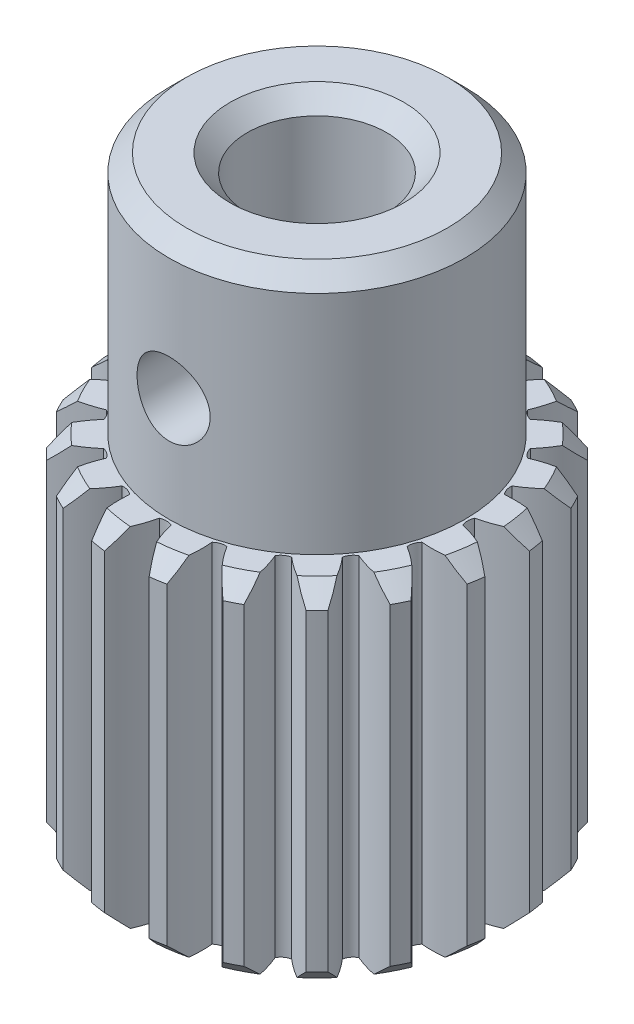
from build123d import *

# Parameters (mm, degrees)
SKETCH_1_R               = 11
EXTRUDE_1_DEPTH          = 20
CUT_EXTRUDE_1_DEPTH      = 21
CHAMFER_1_SIZE           = 1
PATTERN_CIRCULAR_1_COUNT = 20
SKETCH_4_R               = 8.5
EXTRUDE_2_DEPTH          = 14
SKETCH_3_R               = 4
CUT_EXTRUDE_2_DEPTH      = 35
CHAMFER_3_SIZE           = 1
CHAMFER_2_SIZE           = 1
SKETCH_7_W               = 2.1
SKETCH_7_H               = 10.925363506
PATTERN_CIRCULAR_2_COUNT = 2
PATTERN_CIRCULAR_2_ANGLE = 90


with BuildPart() as part:
    # 草圖1 → 填料-伸長1 (new body)
    with BuildSketch(Plane(origin=(0, 0, 0), x_dir=(1, 0, 0), z_dir=(0, 1, 0))):
        Circle(SKETCH_1_R)
    extrude(amount=EXTRUDE_1_DEPTH)

    # 草圖2 → 除料-伸長1 (cut, through all)
    with BuildSketch(Plane(origin=(0, 20, 0), x_dir=(1, 0, 0), z_dir=(0, 1, 0))):
        with BuildLine():
            ThreePointArc((-0.33932507, 8.71883699), (-0.711817342, 9.86361525), (-1.279231123, 10.925363506))
            ThreePointArc((-1.279231123, 10.925363506), (0, 11), (1.279231123, 10.925363506))
            ThreePointArc((1.279231123, 10.925363506), (0.711817342, 9.86361525), (0.33932507, 8.71883699))
            ThreePointArc((0.33932507, 8.71883699), (0, 8.647249963), (-0.33932507, 8.71883699))
        make_face()
    cut_extrude_1 = extrude(amount=-CUT_EXTRUDE_1_DEPTH, mode=Mode.SUBTRACT)

    # 導角1
    chamfer_1_edges = [part.edges().sort_by_distance(p)[0] for p in [
        (0, 0, 11),
        (0, 20, 11),
    ]]
    chamfer(chamfer_1_edges, length=CHAMFER_1_SIZE)

    # 環狀複製排列1: 除料-伸長1 ×20 about axis
    pattern_circular_1_axis = Axis((0, 0, 0), (0, 1, 0))
    for i in range(1, PATTERN_CIRCULAR_1_COUNT):
        add(cut_extrude_1.rotate(pattern_circular_1_axis, i * 360 / PATTERN_CIRCULAR_1_COUNT), mode=Mode.SUBTRACT)

    # 草圖4 → 填料-伸長2 (add)
    with BuildSketch(Plane(origin=(0, 20, 0), x_dir=(1, 0, 0), z_dir=(0, 1, 0))):
        Circle(SKETCH_4_R)
    extrude(amount=EXTRUDE_2_DEPTH)

    # 草圖3 → 除料-伸長2 (cut, through all)
    with BuildSketch(Plane.XZ):
        Circle(SKETCH_3_R)
    extrude(amount=-CUT_EXTRUDE_2_DEPTH, mode=Mode.SUBTRACT)

    # 導角3
    chamfer_3_edges = [part.edges().sort_by_distance(p)[0] for p in [
        (-8.5, 34, 0),
    ]]
    chamfer(chamfer_3_edges, length=CHAMFER_3_SIZE)

    # 導角2
    chamfer_2_edges = [part.edges().sort_by_distance(p)[0] for p in [
        (-4, 34, 0),
        (-4, 0, 0),
    ]]
    chamfer(chamfer_2_edges, length=CHAMFER_2_SIZE)

    # 草圖7 → M5x0.8 螺紋孔1 (revolve, cut)
    with BuildSketch(Plane(origin=(0, 26, 0), x_dir=(0, 1, 0), z_dir=(1, 0, 0))):
        with Locations((1.05, 5.462681753)):
            Rectangle(SKETCH_7_W, SKETCH_7_H)
    m5x0_8_1 = revolve(axis=Axis((0, 26, -6.35), (0, 0, 1)), mode=Mode.SUBTRACT)

    # 環狀複製排列2: M5x0.8 螺紋孔1 ×2 about axis
    pattern_circular_2_axis = Axis((0, 34, 0), (0, -1, 0))
    for i in range(1, PATTERN_CIRCULAR_2_COUNT):
        add(m5x0_8_1.rotate(pattern_circular_2_axis, i * PATTERN_CIRCULAR_2_ANGLE / (PATTERN_CIRCULAR_2_COUNT - 1)), mode=Mode.SUBTRACT)


solid = part.part
